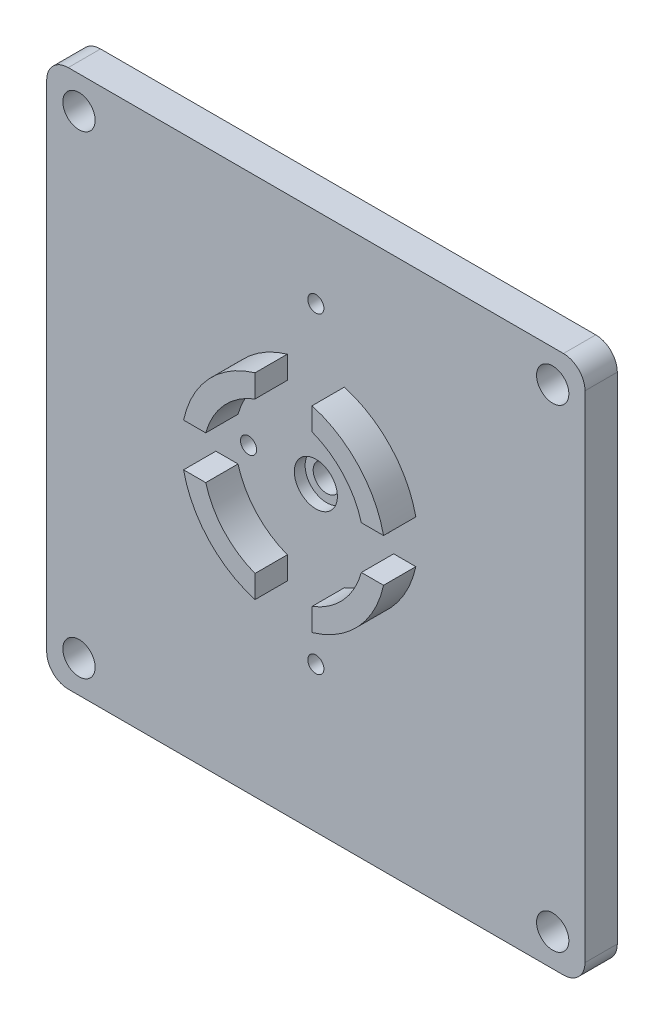
from build123d import *

# Parameters (mm, degrees)
SKETCH_1_R          = 1.5
EXTRUDE_1_DEPTH     = 3
EXTRUDE_2_DEPTH     = 3
SKETCH_3_R          = 1.25
CUT_EXTRUDE_1_DEPTH = 3
SKETCH_4_R          = 0.75
CUT_EXTRUDE_2_DEPTH = 10
CUT_EXTRUDE_START   = -3
SKETCH_5_R          = 2
CUT_EXTRUDE_3_DEPTH = 1


with BuildPart() as part:
    # 草图1 → 凸台-拉伸1 (new body)
    with BuildSketch(Plane.XY):
        with BuildLine():
            Line((-23, 25), (23, 25))
            ThreePointArc((23, 25), (24.414213562, 24.414213562), (25, 23))
            Line((25, 23), (25, -23))
            ThreePointArc((25, -23), (24.414213562, -24.414213562), (23, -25))
            Line((23, -25), (-23, -25))
            ThreePointArc((-23, -25), (-24.414213562, -24.414213562), (-25, -23))
            Line((-25, -23), (-25, 23))
            ThreePointArc((-25, 23), (-24.414213562, 24.414213562), (-23, 25))
        make_face()
        with Locations((-22, 22)):
            Circle(SKETCH_1_R, mode=Mode.SUBTRACT)
        with Locations((22, 22)):
            Circle(SKETCH_1_R, mode=Mode.SUBTRACT)
        with Locations((22, -22)):
            Circle(SKETCH_1_R, mode=Mode.SUBTRACT)
        with Locations((-22, -22)):
            Circle(SKETCH_1_R, mode=Mode.SUBTRACT)
    extrude(amount=EXTRUDE_1_DEPTH)

    # 草图2 → 凸台-拉伸2 (add)
    with BuildSketch(Plane.XY.offset(3)):
        with BuildLine():
            ThreePointArc((2.65, -6.12291072), (6.950358309, -3.476304453), (9.287087811, 1))
            Line((9.287087811, 1), (7.228416147, 1))
            ThreePointArc((7.228416147, 1), (5.53953249, -2.056043887), (2.65, -4.016231182))
            Line((2.65, -4.016231182), (2.65, -6.12291072))
        make_face()
        with BuildLine():
            Line((-7.228416147, 1), (-9.287087811, 1))
            ThreePointArc((-9.287087811, 1), (-6.950358309, -3.476304453), (-2.65, -6.12291072))
            Line((-2.65, -6.12291072), (-2.65, -4.016231182))
            ThreePointArc((-2.65, -4.016231182), (-5.53953249, -2.056043887), (-7.228416147, 1))
        make_face()
        with BuildLine():
            Line((-2.65, 10.016231182), (-2.65, 12.12291072))
            ThreePointArc((-2.65, 12.12291072), (-6.950358309, 9.476304453), (-9.287087811, 5))
            Line((-9.287087811, 5), (-7.228416147, 5))
            ThreePointArc((-7.228416147, 5), (-5.53953249, 8.056043887), (-2.65, 10.016231182))
        make_face()
        with BuildLine():
            ThreePointArc((9.287087811, 5), (6.950358309, 9.476304453), (2.65, 12.12291072))
            Line((2.65, 12.12291072), (2.65, 10.016231182))
            ThreePointArc((2.65, 10.016231182), (5.53953249, 8.056043887), (7.228416147, 5))
            Line((7.228416147, 5), (9.287087811, 5))
        make_face()
    extrude(amount=EXTRUDE_2_DEPTH)

    # 草图3 → 切除-拉伸1 (cut)
    with BuildSketch(Plane.XY.offset(3)):
        with Locations((0, 3)):
            Circle(SKETCH_3_R)
    extrude(amount=-CUT_EXTRUDE_1_DEPTH, mode=Mode.SUBTRACT)

    # 草图4 → 切除-拉伸2 (cut)
    with BuildSketch(Plane.XY.offset(3)):
        with Locations((0, 17.5)):
            Circle(SKETCH_4_R)
        with Locations((0, -11.5)):
            Circle(SKETCH_4_R)
        with Locations((-6.25, 3)):
            Circle(SKETCH_4_R)
        with Locations((6.25, 3)):
            Circle(SKETCH_4_R)
    extrude(amount=-CUT_EXTRUDE_2_DEPTH, mode=Mode.SUBTRACT)

    # 草图5 → 切除-拉伸3 (cut)
    with BuildSketch(Plane(origin=(0, 0, 0), x_dir=(-1, 0, 0), z_dir=(0, 0, -1)).offset(CUT_EXTRUDE_START)):
        with Locations((0, 3)):
            Circle(SKETCH_5_R)
    extrude(amount=CUT_EXTRUDE_3_DEPTH, mode=Mode.SUBTRACT)


solid = part.part
